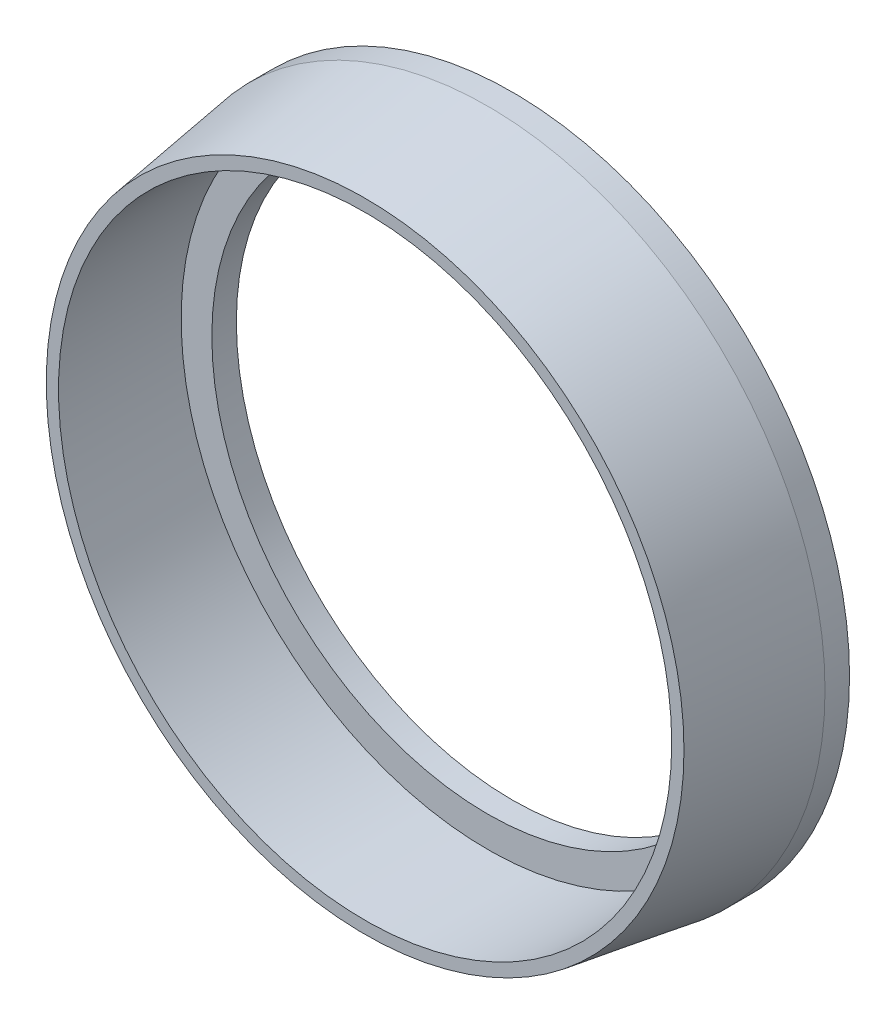
from build123d import *

# Parameters (mm, degrees)
SKETCH_1_R      = 27.5
SKETCH_1_R_2    = 22.5
EXTRUDE_1_DEPTH = 2


with BuildPart() as part:
    # 草圖5 → 旋轉2 (revolve)
    with BuildSketch(Plane(origin=(0, 0, 0), x_dir=(0, 0, -1), z_dir=(1, 0, 0))):
        Polygon((-10, 26), (0, 27.5), (0, 25), (-10, 25), align=None)
    revolve(axis=Axis((0, 0, 10), (0, 0, -1)))

    # 草圖1 → 填料-伸長1 (add)
    with BuildSketch(Plane.XY):
        Circle(SKETCH_1_R)
        Circle(SKETCH_1_R_2, mode=Mode.SUBTRACT)
    extrude(amount=-EXTRUDE_1_DEPTH)


solid = part.part
